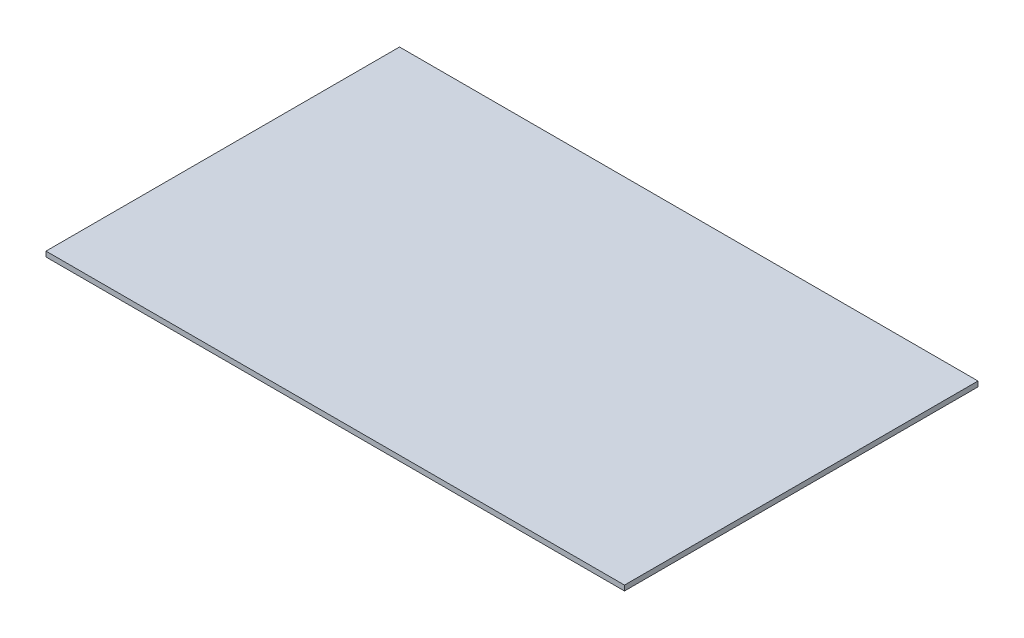
from build123d import *

# Parameters (mm, degrees)
SKETCH1_W           = 180
SKETCH1_H           = 110
BOSS_EXTRUDE1_DEPTH = 1.6


with BuildPart() as part:
    # Sketch1 → Boss-Extrude1 (new body)
    with BuildSketch(Plane(origin=(0, 0, 0), x_dir=(1, 0, 0), z_dir=(0, 1, 0))):
        Rectangle(SKETCH1_W, SKETCH1_H)
    extrude(amount=BOSS_EXTRUDE1_DEPTH)


solid = part.part
